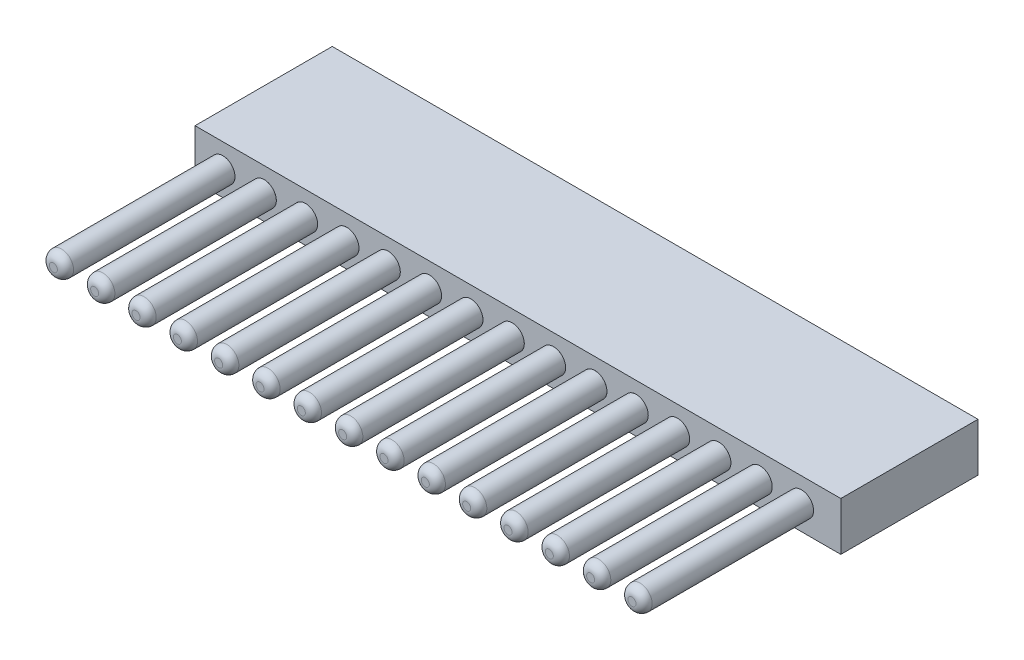
from build123d import *

# Parameters (mm, degrees)
SKETCH1_R              = 0.75
BOSS_EXTRUDE1_DEPTH    = 10.5
BOSS_EXTRUDE1_2_DEPTH  = 10.5
BOSS_EXTRUDE1_3_DEPTH  = 10.5
BOSS_EXTRUDE1_4_DEPTH  = 10.5
BOSS_EXTRUDE1_5_DEPTH  = 10.5
BOSS_EXTRUDE1_6_DEPTH  = 10.5
BOSS_EXTRUDE1_7_DEPTH  = 10.5
BOSS_EXTRUDE1_8_DEPTH  = 10.5
BOSS_EXTRUDE1_9_DEPTH  = 10.5
BOSS_EXTRUDE1_10_DEPTH = 10.5
BOSS_EXTRUDE1_11_DEPTH = 10.5
BOSS_EXTRUDE1_12_DEPTH = 10.5
BOSS_EXTRUDE1_13_DEPTH = 10.5
BOSS_EXTRUDE1_14_DEPTH = 10.5
BOSS_EXTRUDE1_15_DEPTH = 10.5
FILLET1_R              = 0.5
SKETCH2_W              = 40
SKETCH2_H              = 3
SKETCH2_R              = 0.75
BOSS_EXTRUDE2_DEPTH    = 8.5
FILLET2_R              = 0.5
FILLET3_R              = 0.5
FILLET4_R              = 0.5
FILLET5_R              = 0.5
FILLET6_R              = 0.5
FILLET7_R              = 0.5
FILLET8_R              = 0.5
FILLET9_R              = 0.5
FILLET10_R             = 0.5
FILLET11_R             = 0.5
FILLET12_R             = 0.5
FILLET13_R             = 0.5
FILLET14_R             = 0.5
FILLET15_R             = 0.5


with BuildPart() as part:
    # Sketch1 → Boss-Extrude1 (new body)
    with BuildSketch(Plane.XY):
        Circle(SKETCH1_R)
    extrude(amount=BOSS_EXTRUDE1_DEPTH)

    # Fillet1
    fillet1_edges = [part.edges().sort_by_distance(p)[0] for p in [
        (-0.75, 0, 10.5),
    ]]
    fillet(fillet1_edges, radius=FILLET1_R)


with BuildPart() as body_2:
    # Sketch1 → Boss-Extrude1 2 (new body)
    with BuildSketch(Plane.XY):
        with Locations((2.56, 0)):
            Circle(SKETCH1_R)
    extrude(amount=BOSS_EXTRUDE1_2_DEPTH)

    # Fillet2
    fillet2_edges = [body_2.edges().sort_by_distance(p)[0] for p in [
        (1.81, 0, 10.5),
    ]]
    fillet(fillet2_edges, radius=FILLET2_R)


with BuildPart() as body_3:
    # Sketch1 → Boss-Extrude1 3 (new body)
    with BuildSketch(Plane.XY):
        with Locations((5.12, 0)):
            Circle(SKETCH1_R)
    extrude(amount=BOSS_EXTRUDE1_3_DEPTH)

    # Fillet3
    fillet3_edges = [body_3.edges().sort_by_distance(p)[0] for p in [
        (4.37, 0, 10.5),
    ]]
    fillet(fillet3_edges, radius=FILLET3_R)


with BuildPart() as body_4:
    # Sketch1 → Boss-Extrude1 4 (new body)
    with BuildSketch(Plane.XY):
        with Locations((7.68, 0)):
            Circle(SKETCH1_R)
    extrude(amount=BOSS_EXTRUDE1_4_DEPTH)

    # Fillet4
    fillet4_edges = [body_4.edges().sort_by_distance(p)[0] for p in [
        (6.93, 0, 10.5),
    ]]
    fillet(fillet4_edges, radius=FILLET4_R)


with BuildPart() as body_5:
    # Sketch1 → Boss-Extrude1 5 (new body)
    with BuildSketch(Plane.XY):
        with Locations((10.24, 0)):
            Circle(SKETCH1_R)
    extrude(amount=BOSS_EXTRUDE1_5_DEPTH)

    # Fillet5
    fillet5_edges = [body_5.edges().sort_by_distance(p)[0] for p in [
        (9.49, 0, 10.5),
    ]]
    fillet(fillet5_edges, radius=FILLET5_R)


with BuildPart() as body_6:
    # Sketch1 → Boss-Extrude1 6 (new body)
    with BuildSketch(Plane.XY):
        with Locations((12.8, 0)):
            Circle(SKETCH1_R)
    extrude(amount=BOSS_EXTRUDE1_6_DEPTH)

    # Fillet6
    fillet6_edges = [body_6.edges().sort_by_distance(p)[0] for p in [
        (12.05, 0, 10.5),
    ]]
    fillet(fillet6_edges, radius=FILLET6_R)


with BuildPart() as body_7:
    # Sketch1 → Boss-Extrude1 7 (new body)
    with BuildSketch(Plane.XY):
        with Locations((15.36, 0)):
            Circle(SKETCH1_R)
    extrude(amount=BOSS_EXTRUDE1_7_DEPTH)

    # Fillet7
    fillet7_edges = [body_7.edges().sort_by_distance(p)[0] for p in [
        (14.61, 0, 10.5),
    ]]
    fillet(fillet7_edges, radius=FILLET7_R)


with BuildPart() as body_8:
    # Sketch1 → Boss-Extrude1 8 (new body)
    with BuildSketch(Plane.XY):
        with Locations((17.92, 0)):
            Circle(SKETCH1_R)
    extrude(amount=BOSS_EXTRUDE1_8_DEPTH)

    # Fillet8
    fillet8_edges = [body_8.edges().sort_by_distance(p)[0] for p in [
        (17.17, 0, 10.5),
    ]]
    fillet(fillet8_edges, radius=FILLET8_R)


with BuildPart() as body_9:
    # Sketch1 → Boss-Extrude1 9 (new body)
    with BuildSketch(Plane.XY):
        with Locations((20.48, 0)):
            Circle(SKETCH1_R)
    extrude(amount=BOSS_EXTRUDE1_9_DEPTH)

    # Fillet9
    fillet9_edges = [body_9.edges().sort_by_distance(p)[0] for p in [
        (19.73, 0, 10.5),
    ]]
    fillet(fillet9_edges, radius=FILLET9_R)


with BuildPart() as body_10:
    # Sketch1 → Boss-Extrude1 10 (new body)
    with BuildSketch(Plane.XY):
        with Locations((23.04, 0)):
            Circle(SKETCH1_R)
    extrude(amount=BOSS_EXTRUDE1_10_DEPTH)

    # Fillet10
    fillet10_edges = [body_10.edges().sort_by_distance(p)[0] for p in [
        (22.29, 0, 10.5),
    ]]
    fillet(fillet10_edges, radius=FILLET10_R)


with BuildPart() as body_11:
    # Sketch1 → Boss-Extrude1 11 (new body)
    with BuildSketch(Plane.XY):
        with Locations((25.6, 0)):
            Circle(SKETCH1_R)
    extrude(amount=BOSS_EXTRUDE1_11_DEPTH)

    # Fillet11
    fillet11_edges = [body_11.edges().sort_by_distance(p)[0] for p in [
        (24.85, 0, 10.5),
    ]]
    fillet(fillet11_edges, radius=FILLET11_R)


with BuildPart() as body_12:
    # Sketch1 → Boss-Extrude1 12 (new body)
    with BuildSketch(Plane.XY):
        with Locations((28.16, 0)):
            Circle(SKETCH1_R)
    extrude(amount=BOSS_EXTRUDE1_12_DEPTH)

    # Fillet12
    fillet12_edges = [body_12.edges().sort_by_distance(p)[0] for p in [
        (27.41, 0, 10.5),
    ]]
    fillet(fillet12_edges, radius=FILLET12_R)


with BuildPart() as body_13:
    # Sketch1 → Boss-Extrude1 13 (new body)
    with BuildSketch(Plane.XY):
        with Locations((30.72, 0)):
            Circle(SKETCH1_R)
    extrude(amount=BOSS_EXTRUDE1_13_DEPTH)

    # Fillet13
    fillet13_edges = [body_13.edges().sort_by_distance(p)[0] for p in [
        (29.97, 0, 10.5),
    ]]
    fillet(fillet13_edges, radius=FILLET13_R)


with BuildPart() as body_14:
    # Sketch1 → Boss-Extrude1 14 (new body)
    with BuildSketch(Plane.XY):
        with Locations((33.28, 0)):
            Circle(SKETCH1_R)
    extrude(amount=BOSS_EXTRUDE1_14_DEPTH)

    # Fillet14
    fillet14_edges = [body_14.edges().sort_by_distance(p)[0] for p in [
        (32.53, 0, 10.5),
    ]]
    fillet(fillet14_edges, radius=FILLET14_R)


with BuildPart() as body_15:
    # Sketch1 → Boss-Extrude1 15 (new body)
    with BuildSketch(Plane.XY):
        with Locations((35.84, 0)):
            Circle(SKETCH1_R)
    extrude(amount=BOSS_EXTRUDE1_15_DEPTH)

    # Fillet15
    fillet15_edges = [body_15.edges().sort_by_distance(p)[0] for p in [
        (35.09, 0, 10.5),
    ]]
    fillet(fillet15_edges, radius=FILLET15_R)


with BuildPart() as body_16:
    # Sketch2 → Boss-Extrude2 (new body)
    with BuildSketch(Plane(origin=(0, 0, 0), x_dir=(-1, 0, 0), z_dir=(0, 0, -1))):
        with Locations((-18.274877859, 0)):
            Rectangle(SKETCH2_W, SKETCH2_H)
        with Locations((-30.72, 0)):
            Circle(SKETCH2_R, mode=Mode.SUBTRACT)
        with Locations((-28.16, 0)):
            Circle(SKETCH2_R, mode=Mode.SUBTRACT)
        with Locations((-25.6, 0)):
            Circle(SKETCH2_R, mode=Mode.SUBTRACT)
        with Locations((-23.04, 0)):
            Circle(SKETCH2_R, mode=Mode.SUBTRACT)
        with Locations((-20.48, 0)):
            Circle(SKETCH2_R, mode=Mode.SUBTRACT)
        with Locations((-10.24, 0)):
            Circle(SKETCH2_R, mode=Mode.SUBTRACT)
        with Locations((-35.84, 0)):
            Circle(SKETCH2_R, mode=Mode.SUBTRACT)
        with Locations((-33.28, 0)):
            Circle(SKETCH2_R, mode=Mode.SUBTRACT)
        with Locations((-17.92, 0)):
            Circle(SKETCH2_R, mode=Mode.SUBTRACT)
        with Locations((-15.36, 0)):
            Circle(SKETCH2_R, mode=Mode.SUBTRACT)
        with Locations((-12.8, 0)):
            Circle(SKETCH2_R, mode=Mode.SUBTRACT)
        with Locations((-7.68, 0)):
            Circle(SKETCH2_R, mode=Mode.SUBTRACT)
        with Locations((-5.12, 0)):
            Circle(SKETCH2_R, mode=Mode.SUBTRACT)
        with Locations((-2.56, 0)):
            Circle(SKETCH2_R, mode=Mode.SUBTRACT)
        Circle(SKETCH2_R, mode=Mode.SUBTRACT)
    extrude(amount=BOSS_EXTRUDE2_DEPTH)


solid = Compound([part.part, body_2.part, body_3.part, body_4.part, body_5.part, body_6.part, body_7.part, body_8.part, body_9.part, body_10.part, body_11.part, body_12.part, body_13.part, body_14.part, body_15.part, body_16.part])
